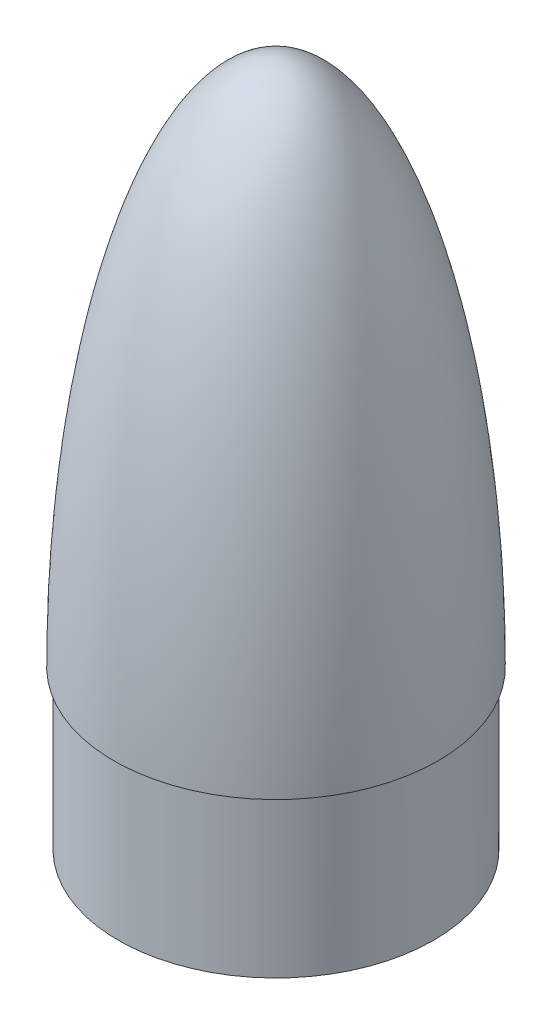
from build123d import *

# Parameters (mm, degrees)
SKETCH2_R               = 76.2
BOSS_EXTRUDE1_DEPTH     = 76.2
SKETCH21_R              = 2.6035
CUT_EXTRUDE4_DEPTH      = 9.525
SKETCH22_R              = 2.6035
CUT_EXTRUDE5_DEPTH      = 9.525
SKETCH27_W              = 38.1
SKETCH27_H              = 38.1
CUT_EXTRUDE7_DEPTH      = 50.8
CUT_EXTRUDE8_DEPTH      = 12.7
CUT_EXTRUDE8_DEPTH_BACK = 12.7
SKETCH28_W              = 38.1
SKETCH28_H              = 38.1
SKETCH29_W              = 50.8
SKETCH29_H              = 50.8
CUT_EXTRUDE9_DEPTH      = 63.5
SKETCH30_R              = 9.525
CUT_EXTRUDE10_DEPTH     = 19.05


with BuildPart() as part:
    # Sketch1 → Revolve1 (revolve)
    with BuildSketch(Plane.XY):
        with BuildLine():
            Line((78.359, 0), (0, 0))
            Line((0, 0), (0, 254))
            add(Edge.make_bspline(
                [(78.359, 0), (78.359, 0.547287489), (78.357845602, 1.649563618), (78.352650776, 3.586349875), (78.338796346, 5.988934596), (78.318010672, 8.352211569), (78.29028895, 10.745600888), (78.246958697, 13.731411826), (78.181061307, 17.311703382), (78.08386626, 21.490442467), (77.944822085, 26.264117007), (77.777683186, 31.037557631), (77.58229134, 35.809557456), (77.358460439, 40.580511863), (77.042853487, 46.542286246), (76.679080298, 52.501436144), (76.266448568, 58.457359127), (75.804102806, 64.409607399), (75.404015228, 69.168949637), (74.865626928, 75.114798701), (74.157385744, 82.243973993), (73.238266918, 90.551730955), (72.055740597, 100.030771811), (70.735528943, 109.491671534), (69.270929118, 118.931305028), (67.249996919, 130.699881306), (64.501732948, 144.763840427), (61.308555538, 158.735984092), (57.591049496, 172.577213574), (53.383025938, 186.275905479), (49.238746312, 198.044837449), (44.48323743, 209.587335711), (38.942884235, 220.71924179), (34.256173135, 228.693595393), (29.818710248, 235.095423042), (25.624249732, 240.182852143), (21.978892835, 243.926180276), (18.570150197, 246.859542723), (15.474349081, 249.076247661), (12.563405711, 250.785701438), (9.772327363, 252.083533871), (7.063069709, 253.028642362), (4.275373805, 253.686778481), (2.188006886, 253.939891173), (0.767171586, 253.999916555), (0, 254)],
                knots=[0.083290168, 0.083290168, 0.083290168, 0.083290168, 0.083290168, 0.091119674, 0.09894918, 0.106778686, 0.114608192, 0.122437698, 0.130267203, 0.145926215, 0.161585227, 0.177244239, 0.192903251, 0.208562263, 0.224221275, 0.239880287, 0.27119831, 0.286857322, 0.302516334, 0.318175346, 0.333834359, 0.365152383, 0.396470407, 0.42778843, 0.459106453, 0.490424474, 0.521742495, 0.584378539, 0.647014581, 0.678332609, 0.709650637, 0.772286631, 0.810589211, 0.841907031, 0.872607503, 0.893486158, 0.91262845, 0.928287274, 0.941044948, 0.952387223, 0.962498308, 0.97249612, 0.981348672, 0.989949856, 1, 1, 1, 1, 1], degree=4))
        make_face()
    revolve(axis=Axis((0, 254, 0), (0, -1, 0)))

    # Sketch2 → Boss-Extrude1 (add)
    with BuildSketch(Plane.XZ):
        Circle(SKETCH2_R)
    extrude(amount=BOSS_EXTRUDE1_DEPTH)

    # Sketch21 → Cut-Extrude4 (cut)
    with BuildSketch(Plane.XZ.offset(76.2)):
        with Locations((-37.81298, 0)):
            Circle(SKETCH21_R)
        with Locations((0, 37.81298)):
            Circle(SKETCH21_R)
        with Locations((37.81298, 0)):
            Circle(SKETCH21_R)
        with Locations((0, -37.81298)):
            Circle(SKETCH21_R)
    extrude(amount=-CUT_EXTRUDE4_DEPTH, mode=Mode.SUBTRACT)

    # Sketch22 → Cut-Extrude5 (cut)
    with BuildSketch(Plane.XZ.offset(76.2)):
        with Locations((-35.921024484, -35.921024484)):
            Circle(SKETCH22_R)
        with Locations((-35.921024484, 35.921024484)):
            Circle(SKETCH22_R)
        with Locations((35.921024484, 35.921024484)):
            Circle(SKETCH22_R)
        with Locations((35.921024484, -35.921024484)):
            Circle(SKETCH22_R)
    extrude(amount=-CUT_EXTRUDE5_DEPTH, mode=Mode.SUBTRACT)

    # Sketch27 → Cut-Extrude7 (cut)
    with BuildSketch(Plane(origin=(0, 44.016832576, -17.279280796), x_dir=(-1, 0, 0), z_dir=(0, -0.9308453589149571, 0.3654133519543104))):
        with Locations((-26.421293772, -9.04130389)):
            Rectangle(SKETCH27_W, SKETCH27_H)
        with Locations((37.219487863, -8.332945695)):
            Rectangle(SKETCH27_W, SKETCH27_H)
        with Locations((-23.648296478, -56.578488001)):
            Rectangle(SKETCH27_W, SKETCH27_H)
        with Locations((24.603212251, -57.8468214)):
            Rectangle(SKETCH27_W, SKETCH27_H)
    extrude(amount=-CUT_EXTRUDE7_DEPTH, mode=Mode.SUBTRACT)

    # Sketch28 → Cut-Extrude8 (cut, two sides: drawn at the far end of the back side and taken through both)
    with BuildSketch(Plane(origin=(0, 20.37336046, -7.997781656), x_dir=(-1, 0, 0), z_dir=(0, -0.9308453589149571, 0.3654133519543104)).offset(-CUT_EXTRUDE8_DEPTH_BACK)):
        with Locations((-22.607200089, 28.533823854)):
            Rectangle(SKETCH28_W, SKETCH28_H)
        with Locations((33.495403265, 12.697844386)):
            Rectangle(SKETCH28_W, SKETCH28_H)
        with Locations((-27.648315988, -27.501194113)):
            Rectangle(SKETCH28_W, SKETCH28_H)
        with Locations((21.868067431, -36.368513827)):
            Rectangle(SKETCH28_W, SKETCH28_H)
    extrude(amount=CUT_EXTRUDE8_DEPTH + CUT_EXTRUDE8_DEPTH_BACK, mode=Mode.SUBTRACT)

    # Sketch29 → Cut-Extrude9 (cut)
    with BuildSketch(Plane(origin=(0, 109.036380897, -42.80340343), x_dir=(-1, 0, 0), z_dir=(0, -0.9308453589149571, 0.3654133519543104))):
        with Locations((-4.810844723, -59.078878237)):
            Rectangle(SKETCH29_W, SKETCH29_H)
    extrude(amount=-CUT_EXTRUDE9_DEPTH, mode=Mode.SUBTRACT)

    # Sketch30 → Cut-Extrude10 (cut)
    with BuildSketch(Plane.XZ.offset(76.2)):
        Circle(SKETCH30_R)
    extrude(amount=-CUT_EXTRUDE10_DEPTH, mode=Mode.SUBTRACT)


solid = part.part
